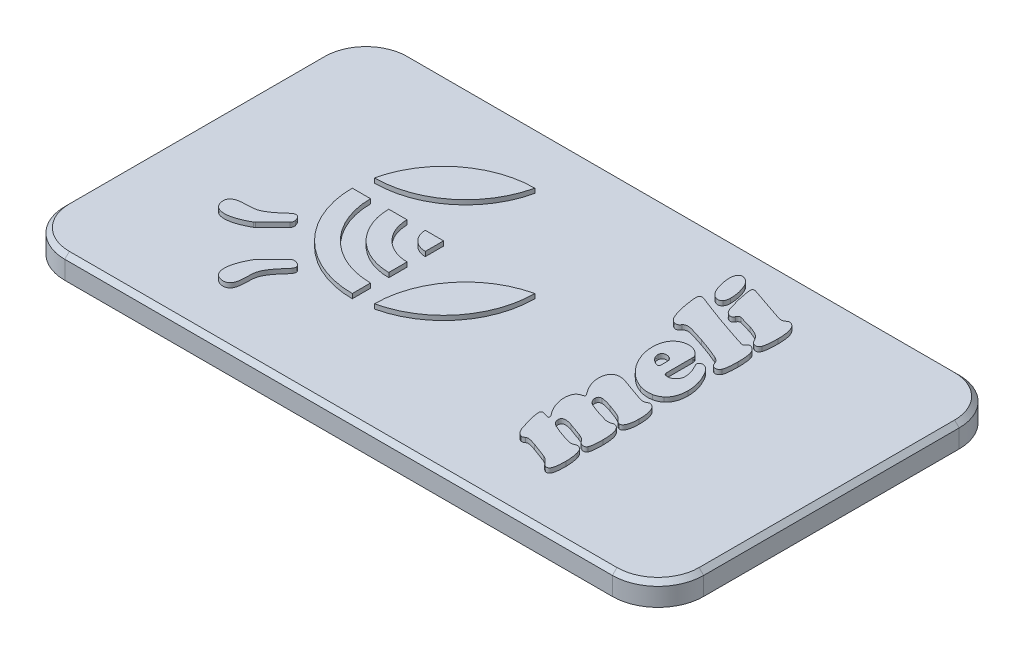
from build123d import *

# Parameters (mm, degrees)
SKETCH1_W           = 140
SKETCH1_H           = 76
BOSS_EXTRUDE1_DEPTH = 5
FILLET1_R           = 10
BOSS_EXTRUDE2_DEPTH = 4
BOSS_EXTRUDE3_DEPTH = 1
BOSS_EXTRUDE4_DEPTH = 1
CHAMFER1_SIZE       = 1
CHAMFER1_SIZE2      = 1.732050808
CHAMFER2_SIZE       = 1


with BuildPart() as part:
    # Sketch1 → Boss-Extrude1 (new body)
    with BuildSketch(Plane(origin=(0, 0, 0), x_dir=(1, 0, 0), z_dir=(0, 1, 0))):
        with Locations((70, 38)):
            Rectangle(SKETCH1_W, SKETCH1_H)
    extrude(amount=BOSS_EXTRUDE1_DEPTH)

    # Fillet1
    fillet1_edges = [part.edges().sort_by_distance(p)[0] for p in [
        (0, 2.5, -76),
        (140, 2.5, -76),
        (140, 2.5, 0),
        (0, 2.5, 0),
    ]]
    fillet(fillet1_edges, radius=FILLET1_R)

    # Sketch3 → Boss-Extrude2 (add)
    with BuildSketch(Plane.XZ):
        with BuildLine():
            Line((5.2, -10), (5.2, -66))
            ThreePointArc((5.2, -66), (6.60588745, -69.39411255), (10, -70.8))
            Line((10, -70.8), (130, -70.8))
            ThreePointArc((130, -70.8), (133.39411255, -69.39411255), (134.8, -66))
            Line((134.8, -66), (134.8, -10))
            ThreePointArc((134.8, -10), (133.39411255, -6.60588745), (130, -5.2))
            Line((130, -5.2), (10, -5.2))
            ThreePointArc((10, -5.2), (6.60588745, -6.60588745), (5.2, -10))
        make_face()
    extrude(amount=BOSS_EXTRUDE2_DEPTH)

    # Sketch4 → Boss-Extrude3 (add)
    with BuildSketch(Plane(origin=(0, 5, 0), x_dir=(1, 0, 0), z_dir=(0, 1, 0))):
        with BuildLine():
            Line((93.75744299, 67.648640731), (100.798454656, 65.255993982))
            add(Edge.make_bspline(
                [(100.798454656, 65.255993982), (100.927750876, 65.212632159), (101.166722633, 65.132488663), (101.501028323, 65.04100066), (101.779213802, 64.985911382), (102.009899704, 64.957677979), (102.211865947, 64.972097631), (102.396898548, 65.024159278), (102.575144929, 65.107802879), (102.679622271, 65.188947152), (102.73347168, 65.230770297)],
                knots=[0, 0, 0, 0, 0.000409091, 0.000756103, 0.001038779, 0.001259646, 0.001451169, 0.00164174, 0.001833533, 0.00203753, 0.00203753, 0.00203753, 0.00203753], degree=3))
            add(Edge.make_bspline(
                [(102.73347168, 65.230770297), (102.81374324, 65.293111417), (102.952677261, 65.401011431), (103.18157613, 65.508967586), (103.424574003, 65.510901816), (103.580209706, 65.462870234), (103.666748047, 65.436163165)],
                knots=[0, 0, 0, 0, 0.000304949, 0.000527806, 0.000744129, 0.001015055, 0.001015055, 0.001015055, 0.001015055], degree=3))
            add(Edge.make_bspline(
                [(103.666748047, 65.436163165), (103.731213011, 65.411534957), (103.859641794, 65.36247), (104.039043833, 65.256108844), (104.201529268, 65.118743483), (104.357172402, 64.961346371), (104.498257245, 64.775766376), (104.623026861, 64.563423892), (104.744137223, 64.329357925), (104.846898934, 64.06561694), (104.936134789, 63.776099336), (105.014853866, 63.462051217), (105.084036038, 63.123248138), (105.1363516, 62.757290393), (105.180521557, 62.365659715), (105.207419542, 61.947180072), (105.226071792, 61.503837726), (105.229074296, 61.199806402), (105.230616554, 61.043638487)],
                knots=[0, 0, 0, 0, 0.000206779, 0.00041195, 0.000621877, 0.000843565, 0.001074913, 0.001319014, 0.00158169, 0.001864733, 0.002166752, 0.002490114, 0.002835682, 0.003203616, 0.003598758, 0.004017743, 0.004461325, 0.004929821, 0.004929821, 0.004929821, 0.004929821], degree=3))
            add(Edge.make_bspline(
                [(105.230616554, 61.043638487), (105.230691629, 60.875455062), (105.230837003, 60.549789434), (105.210169174, 60.076544872), (105.186700222, 59.634279645), (105.151884696, 59.220546753), (105.100584446, 58.838716072), (105.043784482, 58.486231499), (104.976840901, 58.164650202), (104.919439244, 57.962462017), (104.89189849, 57.865454102)],
                knots=[0, 0, 0, 0, 0.000504487, 0.000976874, 0.001420807, 0.00183317, 0.002222018, 0.00257627, 0.002904197, 0.003206646, 0.003206646, 0.003206646, 0.003206646], degree=3))
            add(Edge.make_bspline(
                [(104.89189849, 57.865454102), (104.870039226, 57.806789548), (104.828125162, 57.694303154), (104.732496643, 57.546964913), (104.61366888, 57.42749265), (104.473366542, 57.338093457), (104.315239674, 57.278253495), (104.143908223, 57.257659181), (103.962945634, 57.273219081), (103.844063887, 57.307214745), (103.782056324, 57.324946553)],
                knots=[0, 0, 0, 0, 0.000187376, 0.000359284, 0.000522355, 0.000689281, 0.000854605, 0.001025339, 0.001202492, 0.001395635, 0.001395635, 0.001395635, 0.001395635], degree=3))
            add(Edge.make_bspline(
                [(103.782056324, 57.324946553), (103.683293125, 57.364307529), (103.496152227, 57.438890456), (103.293231234, 57.604597108), (103.153432886, 57.789334291), (103.027796776, 57.992539636), (102.867439184, 58.255099829), (102.757784539, 58.454676612), (102.697437843, 58.564510531)],
                knots=[0, 0, 0, 0, 0.000317609, 0.00060182, 0.000771217, 0.001011106, 0.001318241, 0.001694134, 0.001694134, 0.001694134, 0.001694134], degree=3))
            add(Edge.make_bspline(
                [(102.697437843, 58.564510531), (102.645531185, 58.64652489), (102.539414297, 58.81419333), (102.332620602, 59.04489077), (102.078266793, 59.254368522), (101.778393878, 59.458050237), (101.416896851, 59.652429101), (100.988447696, 59.854436628), (100.480224359, 60.054244627), (100.1142697, 60.182525171), (99.919229043, 60.250894083)],
                knots=[0, 0, 0, 0, 0.000290827, 0.00059456, 0.000924442, 0.001277243, 0.001680435, 0.002154345, 0.00269768, 0.003317713, 0.003317713, 0.003317713, 0.003317713], degree=3))
            add(Edge.make_bspline(
                [(99.919229043, 60.250894083), (99.838861843, 60.277660226), (99.649988701, 60.340564068), (99.319921947, 60.439666541), (98.904441111, 60.567835692), (98.508504977, 60.676420048), (98.178055561, 60.77499692), (97.946819168, 60.838887969), (97.744978499, 60.896380911), (97.57258844, 60.947609837), (97.428510855, 60.987588505), (97.31172202, 61.016596883), (97.223791639, 61.037197602), (97.174641398, 61.049601334), (97.155433779, 61.054448638)],
                knots=[0, 0, 0, 0, 0.000254109, 0.000597188, 0.001033793, 0.001558453, 0.001828707, 0.002068271, 0.002278135, 0.002458304, 0.002607791, 0.002726648, 0.00281929, 0.002878719, 0.002878719, 0.002878719, 0.002878719], degree=3))
            add(Edge.make_bspline(
                [(97.155433779, 61.054448638), (97.076842781, 61.06332278), (96.926387999, 61.080311458), (96.706581601, 60.998062669), (96.523492191, 60.836795764), (96.440027488, 60.690139781), (96.395119827, 60.611232448)],
                knots=[0, 0, 0, 0, 0.000234331, 0.000448603, 0.000681154, 0.000952008, 0.000952008, 0.000952008, 0.000952008], degree=3))
            add(Edge.make_bspline(
                [(96.395119827, 60.611232448), (96.367385127, 60.560169551), (96.314652351, 60.463082207), (96.221733212, 60.33299497), (96.112522381, 60.23507818), (95.993771991, 60.164014329), (95.866293399, 60.119595493), (95.72727033, 60.10546286), (95.579586083, 60.121097711), (95.480699386, 60.149620091), (95.429413007, 60.164412875)],
                knots=[0, 0, 0, 0, 0.000174308, 0.000331418, 0.000476853, 0.000610955, 0.000744281, 0.000878383, 0.001026823, 0.001186758, 0.001186758, 0.001186758, 0.001186758], degree=3))
            add(Edge.make_bspline(
                [(95.429413007, 60.164412875), (95.366206322, 60.189186553), (95.239259886, 60.238942842), (95.060799366, 60.344506752), (94.898441592, 60.480839024), (94.746011035, 60.639392646), (94.609270478, 60.826038791), (94.482434175, 61.036916237), (94.366931935, 61.274199027), (94.30478977, 61.445377364), (94.272726853, 61.533698664)],
                knots=[0, 0, 0, 0, 0.000203456, 0.000408627, 0.000618553, 0.000837738, 0.001066915, 0.001311016, 0.001575319, 0.001857051, 0.001857051, 0.001857051, 0.001857051], degree=3))
            add(Edge.make_bspline(
                [(94.272726853, 61.533698664), (94.104617382, 62.053218735), (93.763733532, 63.106675158), (93.463100671, 64.31559614), (93.290223339, 65.124567129), (93.213171896, 65.502491482), (93.152205349, 65.856003097), (93.103329105, 66.183153248), (93.05707631, 66.483955454), (93.028156583, 66.759314104), (93.014443022, 67.009513362), (93.010027639, 67.166978382), (93.007939189, 67.241458377)],
                knots=[0, 0, 0, 0, 0.00163778, 0.003321008, 0.003733749, 0.004119597, 0.004478003, 0.004809768, 0.005111959, 0.005390913, 0.005639964, 0.00586349, 0.00586349, 0.00586349, 0.00586349], degree=3))
            add(Edge.make_bspline(
                [(93.007939189, 67.241458377), (93.00920326, 67.292209804), (93.011531257, 67.385677046), (93.047949505, 67.51162859), (93.105908048, 67.612363702), (93.194133522, 67.680473539), (93.305448915, 67.715716384), (93.437382981, 67.726209019), (93.591977516, 67.700488543), (93.699026863, 67.666945144), (93.75744299, 67.648640731)],
                knots=[0, 0, 0, 0, 0.000151728, 0.000279432, 0.000389438, 0.000494679, 0.000605216, 0.000735387, 0.000888266, 0.001071897, 0.001071897, 0.001071897, 0.001071897], degree=3))
        make_face()
        with BuildLine():
            add(Edge.make_bspline(
                [(88.395608108, 67.158580553), (88.399719346, 67.324649085), (88.407367351, 67.633581136), (88.480846448, 68.063422373), (88.607987708, 68.421659891), (88.784752301, 68.707918066), (89.008699078, 68.918324305), (89.281013613, 69.030662349), (89.588509978, 69.04799612), (89.789940683, 68.990941763), (89.898219093, 68.960272382)],
                knots=[0, 0, 0, 0, 0.000497906, 0.000926239, 0.001302444, 0.00163132, 0.001927281, 0.002208345, 0.002497178, 0.002832912, 0.002832912, 0.002832912, 0.002832912], degree=3))
            add(Edge.make_bspline(
                [(89.898219093, 68.960272382), (89.977229061, 68.931116964), (90.136043006, 68.872513132), (90.358200684, 68.746352141), (90.572894571, 68.602326797), (90.77616494, 68.432345859), (90.96360548, 68.23305081), (91.134645833, 68.006514228), (91.304723727, 67.762364216), (91.399141673, 67.582529751), (91.447674066, 67.49009185)],
                knots=[0, 0, 0, 0, 0.000252263, 0.00050706, 0.000763914, 0.001027355, 0.001300096, 0.001582634, 0.001878463, 0.002191356, 0.002191356, 0.002191356, 0.002191356], degree=3))
            add(Edge.make_bspline(
                [(91.447674066, 67.49009185), (91.516858042, 67.340766231), (91.655742184, 67.04100086), (91.829271624, 66.576469206), (91.982852338, 66.103562817), (92.105324651, 65.619624851), (92.197940585, 65.124742321), (92.267452995, 64.619819073), (92.306937535, 64.103544029), (92.313020425, 63.755848974), (92.316089527, 63.580420582)],
                knots=[0, 0, 0, 0, 0.000493558, 0.000990799, 0.00148651, 0.001984664, 0.002487139, 0.002996237, 0.003513043, 0.004039335, 0.004039335, 0.004039335, 0.004039335], degree=3))
            add(Edge.make_bspline(
                [(92.316089527, 63.580420582), (92.312666953, 63.44074219), (92.306308451, 63.181245833), (92.242266082, 62.821392601), (92.135816089, 62.518019802), (92.020588371, 62.355704291), (91.966561312, 62.279599082)],
                knots=[0, 0, 0, 0, 0.000418551, 0.00077759, 0.001093478, 0.001372339, 0.001372339, 0.001372339, 0.001372339], degree=3))
            add(Edge.make_bspline(
                [(91.966561312, 62.279599082), (91.928183012, 62.236331323), (91.853418592, 62.152041794), (91.722649762, 62.048854276), (91.579119273, 61.978168336), (91.427608022, 61.922931641), (91.261948879, 61.904615067), (91.086327087, 61.908382317), (90.900885971, 61.937733224), (90.777046193, 61.975350717), (90.7125838, 61.994931773)],
                knots=[0, 0, 0, 0, 0.000173337, 0.000337677, 0.00049561, 0.000651725, 0.000818884, 0.000991884, 0.001177904, 0.001379854, 0.001379854, 0.001379854, 0.001379854], degree=3))
            add(Edge.make_bspline(
                [(90.7125838, 61.994931773), (90.623415958, 62.029136134), (90.443792458, 62.098038856), (90.196160725, 62.260220817), (89.960713493, 62.459174753), (89.74096452, 62.702071065), (89.54021662, 62.987575569), (89.346085816, 63.30921341), (89.176521993, 63.678773021), (89.075188101, 63.941391345), (89.022596864, 64.077687526)],
                knots=[0, 0, 0, 0, 0.000285783, 0.000575693, 0.00088251, 0.001209009, 0.001555009, 0.001928268, 0.002334476, 0.002772758, 0.002772758, 0.002772758, 0.002772758], degree=3))
            add(Edge.make_bspline(
                [(89.022596864, 64.077687526), (88.926708247, 64.3586052), (88.742494735, 64.898281676), (88.550656414, 65.696726213), (88.420572116, 66.443270995), (88.403715373, 66.926277959), (88.395608108, 67.158580553)],
                knots=[0, 0, 0, 0, 0.000889977, 0.001709753, 0.002461514, 0.003158096, 0.003158096, 0.003158096, 0.003158096], degree=3))
        make_face()
        with BuildLine():
            Line((95.35374195, 58.344704128), (99.256206451, 57.018658942))
            add(Edge.make_bspline(
                [(99.256206451, 57.018658942), (99.460216864, 56.948453708), (99.844887306, 56.816078709), (100.391401923, 56.637088868), (100.868862671, 56.477955891), (101.279649157, 56.344605915), (101.621872249, 56.236117999), (101.895616994, 56.152822692), (102.101968078, 56.093823372), (102.283109981, 56.049090702), (102.460043223, 56.031763896), (102.646300506, 56.071559597), (102.806152093, 56.171419791), (102.883908535, 56.268818492), (102.924451014, 56.319602513)],
                knots=[0, 0, 0, 0, 0.000647246, 0.001220411, 0.001725206, 0.002157086, 0.002516071, 0.002802194, 0.003015526, 0.003159751, 0.003362055, 0.003543015, 0.003721009, 0.003914923, 0.003914923, 0.003914923, 0.003914923], degree=3))
            add(Edge.make_bspline(
                [(102.924451014, 56.319602513), (102.954581734, 56.364857555), (103.010663546, 56.44909002), (103.103216774, 56.552996299), (103.192349874, 56.629442333), (103.282279554, 56.680714778), (103.38462602, 56.702884557), (103.499157778, 56.699537703), (103.632018641, 56.682779782), (103.722407864, 56.652864069), (103.771246173, 56.636700274)],
                knots=[0, 0, 0, 0, 0.000162951, 0.000303298, 0.000415871, 0.000514225, 0.000610375, 0.000725683, 0.00085665, 0.001010587, 0.001010587, 0.001010587, 0.001010587], degree=3))
            add(Edge.make_bspline(
                [(103.771246173, 56.636700274), (103.838313447, 56.611201963), (103.974070149, 56.559588614), (104.162805048, 56.44064893), (104.340640914, 56.290209976), (104.507496977, 56.112363271), (104.657081329, 55.910957197), (104.789988314, 55.694753754), (104.889140645, 55.458961911), (104.938943098, 55.295496396), (104.963966163, 55.21336373)],
                knots=[0, 0, 0, 0, 0.000214817, 0.00043483, 0.000665052, 0.000912324, 0.001164561, 0.001416695, 0.001671722, 0.001929257, 0.001929257, 0.001929257, 0.001929257], degree=3))
            add(Edge.make_bspline(
                [(104.963966163, 55.21336373), (104.985327097, 55.129495137), (105.030824366, 54.950861), (105.082662522, 54.66296506), (105.129222941, 54.34206605), (105.169290646, 53.987677504), (105.197662307, 53.599409858), (105.212846467, 53.177509335), (105.230169734, 52.722356128), (105.230463895, 52.407549312), (105.230616554, 52.244175596)],
                knots=[0, 0, 0, 0, 0.000259569, 0.000552863, 0.000876967, 0.001232316, 0.001622548, 0.002044529, 0.002498784, 0.002988857, 0.002988857, 0.002988857, 0.002988857], degree=3))
            add(Edge.make_bspline(
                [(105.230616554, 52.244175596), (105.228617815, 52.061602782), (105.224790684, 51.712017273), (105.212940054, 51.210818596), (105.183572468, 50.756609638), (105.144652833, 50.347924361), (105.095603407, 49.984528675), (105.0347882, 49.66691468), (104.966282151, 49.394460603), (104.902995252, 49.233654383), (104.873881572, 49.159679186)],
                knots=[0, 0, 0, 0, 0.000547762, 0.001048839, 0.00150378, 0.001912887, 0.002280308, 0.002603269, 0.002882967, 0.003121254, 0.003121254, 0.003121254, 0.003121254], degree=3))
            add(Edge.make_bspline(
                [(104.873881572, 49.159679186), (104.845984575, 49.100796311), (104.792001873, 48.986853701), (104.676630234, 48.838589589), (104.537542664, 48.718716155), (104.380281676, 48.625650172), (104.21046272, 48.562794581), (104.032862129, 48.538734052), (103.849552101, 48.542852345), (103.731081488, 48.579014168), (103.670351431, 48.597551336)],
                knots=[0, 0, 0, 0, 0.000195016, 0.00037737, 0.000558724, 0.000742885, 0.000922982, 0.001097774, 0.001278087, 0.001467736, 0.001467736, 0.001467736, 0.001467736], degree=3))
            add(Edge.make_bspline(
                [(103.670351431, 48.597551336), (103.580960445, 48.634376458), (103.4093948, 48.705053897), (103.231223638, 48.869026208), (103.124027754, 49.045318279), (103.03567201, 49.223767259), (102.932963152, 49.446926698), (102.87146171, 49.615560446), (102.837969806, 49.707393502)],
                knots=[0, 0, 0, 0, 0.000288473, 0.000553659, 0.000707595, 0.000905814, 0.00115095, 0.001444067, 0.001444067, 0.001444067, 0.001444067], degree=3))
            add(Edge.make_bspline(
                [(102.837969806, 49.707393502), (102.791965912, 49.800506957), (102.694473139, 49.997835664), (102.439304247, 50.251639478), (102.104243754, 50.489851373), (101.838639934, 50.618355477), (101.695697186, 50.687513857)],
                knots=[0, 0, 0, 0, 0.000309744, 0.000656419, 0.001064414, 0.001539869, 0.001539869, 0.001539869, 0.001539869], degree=3))
            add(Edge.make_bspline(
                [(101.695697186, 50.687513857), (101.55530078, 50.75027832), (101.262137795, 50.881337355), (100.800446513, 51.080234462), (100.29576502, 51.285384981), (99.748005171, 51.496070748), (99.160525485, 51.721188805), (98.529577756, 51.950998171), (97.855796297, 52.189088929), (97.391032483, 52.34678567), (97.151830395, 52.427948163)],
                knots=[0, 0, 0, 0, 0.00046136, 0.000963369, 0.001508053, 0.002095581, 0.002723987, 0.003395426, 0.004109996, 0.004867778, 0.004867778, 0.004867778, 0.004867778], degree=3))
            add(Edge.make_bspline(
                [(97.151830395, 52.427948163), (96.914153938, 52.508857485), (96.461093945, 52.663087219), (95.812635835, 52.87631299), (95.229235388, 53.058652456), (94.714726609, 53.21863292), (94.266858277, 53.349179134), (93.885152245, 53.451707812), (93.568587152, 53.523130515), (93.248733666, 53.587226583), (92.912319668, 53.614748805), (92.556108134, 53.558394094), (92.244992979, 53.421423791), (92.09551724, 53.263698109), (92.020612067, 53.184658731)],
                knots=[0, 0, 0, 0, 0.000753211, 0.001435774, 0.002047766, 0.00258689, 0.003052159, 0.003447219, 0.003772403, 0.004025411, 0.004426181, 0.004776878, 0.005099275, 0.005423119, 0.005423119, 0.005423119, 0.005423119], degree=3))
            add(Edge.make_bspline(
                [(92.020612067, 53.184658731), (91.974036902, 53.12449712), (91.886326215, 53.01120034), (91.741502541, 52.871914633), (91.605448094, 52.762502561), (91.465287499, 52.693117584), (91.319715779, 52.660437771), (91.163242086, 52.657956313), (90.993551933, 52.684893197), (90.877965246, 52.719572451), (90.817081926, 52.737839158)],
                knots=[0, 0, 0, 0, 0.000227926, 0.000429233, 0.000601481, 0.000749746, 0.000893971, 0.001045356, 0.001216583, 0.001407154, 0.001407154, 0.001407154, 0.001407154], degree=3))
            add(Edge.make_bspline(
                [(90.817081926, 52.737839158), (90.724783505, 52.775920188), (90.534570358, 52.854399456), (90.280490841, 53.056581163), (90.041021871, 53.31416254), (89.82436917, 53.643479081), (89.62287808, 54.043526579), (89.43029208, 54.518320325), (89.251335588, 55.074439427), (89.14666691, 55.473437356), (89.091061154, 55.685406989)],
                knots=[0, 0, 0, 0, 0.000298233, 0.000614613, 0.000963919, 0.001350691, 0.001792264, 0.002306172, 0.002886183, 0.003543541, 0.003543541, 0.003543541, 0.003543541], degree=3))
            add(Edge.make_bspline(
                [(89.091061154, 55.685406989), (89.046499557, 55.848428022), (88.95260226, 56.191935337), (88.832281209, 56.740597813), (88.718001371, 57.347761904), (88.610083563, 57.987967167), (88.521465463, 58.60947723), (88.450474903, 59.158054311), (88.407966054, 59.607643049), (88.399361423, 59.874881715), (88.395608108, 59.991450459)],
                knots=[0, 0, 0, 0, 0.000506939, 0.001068188, 0.00168444, 0.002360361, 0.003015701, 0.003567678, 0.004019841, 0.004369667, 0.004369667, 0.004369667, 0.004369667], degree=3))
            add(Edge.make_bspline(
                [(88.395608108, 59.991450459), (88.397766129, 60.064171402), (88.401737666, 60.1980042), (88.46215981, 60.376458937), (88.551630477, 60.522611405), (88.69631535, 60.609611309), (88.870257023, 60.656417757), (89.079683418, 60.661172434), (89.322918031, 60.616421655), (89.49279342, 60.563954817), (89.584724715, 60.535561391)],
                knots=[0, 0, 0, 0, 0.000216952, 0.000399271, 0.000560177, 0.000719094, 0.000891342, 0.001096861, 0.00134152, 0.001630083, 0.001630083, 0.001630083, 0.001630083], degree=3))
            add(Edge.make_bspline(
                [(89.584724715, 60.535561391), (89.621964712, 60.522366959), (89.708630935, 60.491660414), (89.853604881, 60.439757475), (90.028181007, 60.367328101), (90.237391132, 60.292333761), (90.474880961, 60.19053334), (90.746531332, 60.085936633), (91.049541195, 59.965413086), (91.260388682, 59.878768041), (91.372003009, 59.832901578)],
                knots=[0, 0, 0, 0, 0.000118529, 0.000275845, 0.000461864, 0.00068539, 0.000942345, 0.001236766, 0.001558619, 0.001920629, 0.001920629, 0.001920629, 0.001920629], degree=3))
            add(Edge.make_bspline(
                [(91.372003009, 59.832901578), (91.725985408, 59.693858411), (92.418219663, 59.421950984), (93.438238927, 59.038956544), (94.409183962, 58.675483478), (95.044666531, 58.45294075), (95.35374195, 58.344704128)],
                knots=[0, 0, 0, 0, 0.001140913, 0.002231126, 0.003268625, 0.004251035, 0.004251035, 0.004251035, 0.004251035], degree=3))
        make_face()
        with BuildLine():
            Line((99.465202703, 48.139921611), (99.465202703, 42.338473923))
            add(Edge.make_bspline(
                [(99.465202703, 42.338473923), (99.468548063, 42.280030132), (99.474955907, 42.168084436), (99.546636654, 42.016756956), (99.667758842, 41.900412084), (99.770697133, 41.857084487), (99.825541068, 41.834000211)],
                knots=[0, 0, 0, 0, 0.000174308, 0.000333878, 0.000489325, 0.000666588, 0.000666588, 0.000666588, 0.000666588], degree=3))
            add(Edge.make_bspline(
                [(99.825541068, 41.834000211), (99.897070654, 41.811232744), (100.036893031, 41.766728065), (100.252355173, 41.740773678), (100.462806185, 41.73504244), (100.670396686, 41.760825016), (100.874796553, 41.81648614), (101.076566244, 41.898614934), (101.273202132, 42.014077638), (101.465108641, 42.151510421), (101.641860708, 42.312864631), (101.802776103, 42.483611259), (101.932733594, 42.672803689), (102.046705747, 42.868308382), (102.128732257, 43.081864661), (102.190516981, 43.304878525), (102.227405086, 43.540780979), (102.230849519, 43.701625523), (102.232601351, 43.78343077)],
                knots=[0, 0, 0, 0, 0.000224714, 0.000439259, 0.000648286, 0.000855222, 0.001064125, 0.001282271, 0.001506638, 0.001746662, 0.001989055, 0.00222369, 0.002448635, 0.002676134, 0.002900963, 0.003132619, 0.003369594, 0.003614863, 0.003614863, 0.003614863, 0.003614863], degree=3))
            add(Edge.make_bspline(
                [(102.232601351, 43.78343077), (102.229877707, 43.88809708), (102.224186399, 44.106807007), (102.17256012, 44.446041922), (102.097671608, 44.812293126), (101.9886387, 45.194470037), (101.868262657, 45.581252631), (101.723463911, 45.945980723), (101.569564336, 46.285472004), (101.450985079, 46.495159468), (101.393012959, 46.597673406)],
                knots=[0, 0, 0, 0, 0.000313826, 0.000655767, 0.001027493, 0.001434866, 0.001847387, 0.002242184, 0.002611385, 0.002964535, 0.002964535, 0.002964535, 0.002964535], degree=3))
            add(Edge.make_bspline(
                [(101.393012959, 46.597673406), (101.345842594, 46.679825042), (101.259817902, 46.829645151), (101.163012609, 47.044451484), (101.093238045, 47.221629258), (101.083622354, 47.332353084), (101.079518581, 47.379607659)],
                knots=[0, 0, 0, 0, 0.000283845, 0.000517649, 0.000707947, 0.000849629, 0.000849629, 0.000849629, 0.000849629], degree=3))
            add(Edge.make_bspline(
                [(101.079518581, 47.379607659), (101.08263385, 47.432376987), (101.088767013, 47.536266191), (101.171358813, 47.675983401), (101.290170834, 47.798159511), (101.451413115, 47.893934145), (101.634980301, 47.966237997), (101.830080034, 47.998331541), (102.029141909, 47.992271674), (102.156229968, 47.956556567), (102.2217912, 47.938132126)],
                knots=[0, 0, 0, 0, 0.000156447, 0.000308003, 0.000473641, 0.000664621, 0.000865378, 0.001062645, 0.00125376, 0.001457407, 0.001457407, 0.001457407, 0.001457407], degree=3))
            add(Edge.make_bspline(
                [(102.2217912, 47.938132126), (102.292405417, 47.911318827), (102.438652969, 47.855786392), (102.646309331, 47.729607983), (102.85401129, 47.574041584), (103.054820125, 47.379914859), (103.25663212, 47.155667293), (103.459267009, 46.899209672), (103.656607123, 46.606981202), (103.779653101, 46.396618518), (103.843313846, 46.287782411)],
                knots=[0, 0, 0, 0, 0.000226182, 0.000468441, 0.000725724, 0.001003558, 0.001304608, 0.001630451, 0.001983251, 0.002361452, 0.002361452, 0.002361452, 0.002361452], degree=3))
            add(Edge.make_bspline(
                [(103.843313846, 46.287782411), (103.954080612, 46.087350404), (104.173023878, 45.691173466), (104.451772527, 45.07920396), (104.697397179, 44.466603754), (104.889737079, 43.846487981), (105.043526606, 43.22345796), (105.150265857, 42.597205125), (105.218377467, 41.966432535), (105.226527775, 41.544700793), (105.230616554, 41.333129883)],
                knots=[0, 0, 0, 0, 0.000686764, 0.001357468, 0.002015901, 0.002665511, 0.003303503, 0.003939743, 0.004570077, 0.005204641, 0.005204641, 0.005204641, 0.005204641], degree=3))
            add(Edge.make_bspline(
                [(105.230616554, 41.333129883), (105.226962571, 41.126343593), (105.219866649, 40.724770997), (105.151011785, 40.143258071), (105.036204007, 39.604017791), (104.878296243, 39.105477142), (104.672384, 38.647664964), (104.418870063, 38.231979734), (104.122532069, 37.853516659), (103.888516201, 37.639039111), (103.771246173, 37.531560125)],
                knots=[0, 0, 0, 0, 0.000620159, 0.00120433, 0.001753476, 0.002271976, 0.002770299, 0.003255419, 0.003729822, 0.004206355, 0.004206355, 0.004206355, 0.004206355], degree=3))
            add(Edge.make_bspline(
                [(103.771246173, 37.531560125), (103.649044302, 37.434969539), (103.40346398, 37.240858377), (102.981208357, 37.021920108), (102.528447141, 36.839408437), (102.206309168, 36.765691835), (102.041622018, 36.728005569)],
                knots=[0, 0, 0, 0, 0.000466287, 0.000937063, 0.001420857, 0.001926885, 0.001926885, 0.001926885, 0.001926885], degree=3))
            add(Edge.make_bspline(
                [(102.041622018, 36.728005569), (101.813913378, 36.693397101), (101.354148664, 36.623519417), (100.645537176, 36.647122111), (99.919364309, 36.75196426), (99.443242085, 36.897989862), (99.198552312, 36.973035658)],
                knots=[0, 0, 0, 0, 0.000689641, 0.001392449, 0.002117624, 0.002884341, 0.002884341, 0.002884341, 0.002884341], degree=3))
            add(Edge.make_bspline(
                [(99.198552312, 36.973035658), (99.032972638, 37.03297981), (98.700557294, 37.153322817), (98.218448575, 37.380421451), (97.744743608, 37.63453911), (97.287491679, 37.9282587), (96.84179497, 38.253845953), (96.409304918, 38.615693682), (95.987226374, 39.010698639), (95.722006855, 39.296769825), (95.587961888, 39.441353463)],
                knots=[0, 0, 0, 0, 0.000528028, 0.001060061, 0.001596977, 0.002139762, 0.002688956, 0.003251823, 0.003830488, 0.004421817, 0.004421817, 0.004421817, 0.004421817], degree=3))
            add(Edge.make_bspline(
                [(95.587961888, 39.441353463), (95.365913745, 39.699924598), (94.925315508, 40.212993452), (94.371404835, 41.056680839), (93.889521508, 41.933870921), (93.64539289, 42.551755283), (93.523223052, 42.860964553)],
                knots=[0, 0, 0, 0, 0.001021488, 0.002026883, 0.003021639, 0.004018117, 0.004018117, 0.004018117, 0.004018117], degree=3))
            add(Edge.make_bspline(
                [(93.523223052, 42.860964553), (93.442744527, 43.096223204), (93.283343305, 43.562192431), (93.130116541, 44.280504394), (93.026236776, 44.999525614), (93.014032086, 45.481458048), (93.007939189, 45.722051177)],
                knots=[0, 0, 0, 0, 0.000745282, 0.001476156, 0.0021998, 0.002921206, 0.002921206, 0.002921206, 0.002921206], degree=3))
            add(Edge.make_bspline(
                [(93.007939189, 45.722051177), (93.012603391, 45.908342755), (93.021683967, 46.271027431), (93.077143948, 46.798533312), (93.179729731, 47.289823893), (93.313982025, 47.747867988), (93.495095749, 48.168588162), (93.717883024, 48.552067942), (93.971504821, 48.908443631), (94.177114537, 49.111958451), (94.27993362, 49.213729941)],
                knots=[0, 0, 0, 0, 0.000558943, 0.001088186, 0.001588525, 0.00206275, 0.002517919, 0.002958608, 0.003391765, 0.003825041, 0.003825041, 0.003825041, 0.003825041], degree=3))
            add(Edge.make_bspline(
                [(94.27993362, 49.213729941), (94.389409405, 49.307942899), (94.606616716, 49.494867736), (94.972282809, 49.723631031), (95.36725578, 49.903546762), (95.647906857, 49.979099308), (95.789751372, 50.017284496)],
                knots=[0, 0, 0, 0, 0.000432781, 0.000858667, 0.001289298, 0.001729353, 0.001729353, 0.001729353, 0.001729353], degree=3))
            add(Edge.make_bspline(
                [(95.789751372, 50.017284496), (95.952483299, 50.050096765), (96.274528296, 50.115031945), (96.765503914, 50.120994831), (97.251644711, 50.066881451), (97.563657729, 49.974058073), (97.721165013, 49.927199905)],
                knots=[0, 0, 0, 0, 0.000497019, 0.000983596, 0.001466301, 0.001958384, 0.001958384, 0.001958384, 0.001958384], degree=3))
            add(Edge.make_bspline(
                [(97.721165013, 49.927199905), (97.844985335, 49.882171058), (98.086605253, 49.794302878), (98.419209772, 49.614840243), (98.718002433, 49.409527806), (98.975481713, 49.17551637), (99.191568073, 48.930446764), (99.347048648, 48.671929726), (99.4495508, 48.40930645), (99.460058109, 48.228465198), (99.465202703, 48.139921611)],
                knots=[0, 0, 0, 0, 0.000394797, 0.000770397, 0.001130248, 0.001479776, 0.001811992, 0.002106148, 0.002381989, 0.002646611, 0.002646611, 0.002646611, 0.002646611], degree=3))
        make_face()
        with BuildLine():
            Line((97.389653716, 43.444712706), (97.389653716, 44.659052998))
            add(Edge.make_bspline(
                [(97.389653716, 44.659052998), (97.388053777, 44.72052077), (97.38494898, 44.839803362), (97.347541983, 45.009709651), (97.290141237, 45.165167002), (97.205470495, 45.304239051), (97.096644403, 45.427132692), (96.964857448, 45.532639457), (96.810102151, 45.620657037), (96.696105547, 45.66358767), (96.636546532, 45.686017341)],
                knots=[0, 0, 0, 0, 0.00018409, 0.00035724, 0.000519192, 0.000679249, 0.000842638, 0.001009214, 0.001183522, 0.001374229, 0.001374229, 0.001374229, 0.001374229], degree=3))
            add(Edge.make_bspline(
                [(96.636546532, 45.686017341), (96.528156183, 45.720255692), (96.325137721, 45.78438518), (96.023108068, 45.812537958), (95.751061713, 45.793538805), (95.515059668, 45.704775125), (95.32104018, 45.565600482), (95.17764744, 45.374160104), (95.0989235, 45.13190042), (95.088858479, 44.957499444), (95.083488176, 44.864445867)],
                knots=[0, 0, 0, 0, 0.000340057, 0.000636937, 0.000904778, 0.001151077, 0.001383153, 0.001612329, 0.00185619, 0.002135144, 0.002135144, 0.002135144, 0.002135144], degree=3))
            add(Edge.make_bspline(
                [(95.083488176, 44.864445867), (95.09059116, 44.75308704), (95.104805831, 44.530232936), (95.216764304, 44.205032901), (95.39642883, 43.89377285), (95.560307386, 43.709826744), (95.645616026, 43.614071738)],
                knots=[0, 0, 0, 0, 0.000333464, 0.000667336, 0.001020872, 0.00140473, 0.00140473, 0.00140473, 0.00140473], degree=3))
            add(Edge.make_bspline(
                [(95.645616026, 43.614071738), (95.731663578, 43.530504759), (95.897066259, 43.369870297), (96.162160092, 43.168106105), (96.425113584, 43.002551516), (96.611185225, 42.931466173), (96.701407438, 42.89699839)],
                knots=[0, 0, 0, 0, 0.000359491, 0.000691021, 0.000998156, 0.001287259, 0.001287259, 0.001287259, 0.001287259], degree=3))
            add(Edge.make_bspline(
                [(96.701407438, 42.89699839), (96.759752733, 42.877501628), (96.865262045, 42.842244458), (97.015511076, 42.830068861), (97.140850616, 42.832911604), (97.239809168, 42.88537728), (97.314486577, 42.973034886), (97.355309548, 43.099743047), (97.384999322, 43.259504953), (97.387987895, 43.378426301), (97.389653716, 43.444712706)],
                knots=[0, 0, 0, 0, 0.000183631, 0.000332071, 0.000451473, 0.00055301, 0.000657756, 0.000788921, 0.000946525, 0.001145006, 0.001145006, 0.001145006, 0.001145006], degree=3))
        make_face(mode=Mode.SUBTRACT)
        with BuildLine():
            add(Edge.make_bspline(
                [(93.007939189, 20.905547931), (93.010195601, 20.956277625), (93.014329988, 21.049228831), (93.056421073, 21.176508856), (93.138162178, 21.268924727), (93.248092207, 21.327106725), (93.384830203, 21.355909544), (93.550148277, 21.34808854), (93.743401364, 21.310556513), (93.879168992, 21.267416262), (93.952025707, 21.244265995)],
                knots=[0, 0, 0, 0, 0.000152027, 0.000278556, 0.00039347, 0.000512818, 0.000645704, 0.000807896, 0.001005787, 0.001234964, 0.001234964, 0.001234964, 0.001234964], degree=3))
            add(Edge.make_bspline(
                [(93.952025707, 21.244265995), (93.970055075, 21.238296794), (94.036408528, 21.216328353), (94.102256127, 21.192879271), (94.150211808, 21.175801705)],
                knots=[0, 0, 0, 0, 5.6974e-05, 0.000209683, 0.000209683, 0.000209683, 0.000209683], degree=3))
            add(Edge.make_bspline(
                [(94.150211808, 21.175801705), (94.206640627, 21.154117853), (94.307424236, 21.115389824), (94.408439357, 21.077269954), (94.452896036, 21.060493428)],
                knots=[0, 0, 0, 0, 0.000181354, 0.000323905, 0.000323905, 0.000323905, 0.000323905], degree=3))
            add(Edge.make_bspline(
                [(94.452896036, 21.060493428), (94.501913227, 21.045350631), (94.591884924, 21.017555828), (94.719499242, 20.989313617), (94.829323449, 20.98529504), (94.920803633, 20.997578405), (94.994437449, 21.0297301), (95.045945654, 21.085764274), (95.07406914, 21.161451029), (95.077848135, 21.217605436), (95.079884792, 21.247869378)],
                knots=[0, 0, 0, 0, 0.000153937, 0.000282553, 0.000390714, 0.000481945, 0.000557701, 0.000626544, 0.000704163, 0.000794894, 0.000794894, 0.000794894, 0.000794894], degree=3))
            add(Edge.make_bspline(
                [(95.079884792, 21.247869378), (95.071022315, 21.292997245), (95.048836614, 21.405967173), (94.941958838, 21.587854444), (94.787735457, 21.823241504), (94.654071178, 21.990137188), (94.579014464, 22.083854387)],
                knots=[0, 0, 0, 0, 0.000137213, 0.000343489, 0.000624322, 0.000983975, 0.000983975, 0.000983975, 0.000983975], degree=3))
            add(Edge.make_bspline(
                [(94.579014464, 22.083854387), (94.461816144, 22.240319727), (94.226343256, 22.55468725), (93.926664735, 23.068584415), (93.654252193, 23.607425156), (93.427918049, 24.173822188), (93.238070013, 24.746621075), (93.112121879, 25.319462277), (93.021059147, 25.877720848), (93.012259774, 26.247814972), (93.007939189, 26.429535077)],
                knots=[0, 0, 0, 0, 0.000586024, 0.001177429, 0.001781735, 0.002396003, 0.003005657, 0.003589583, 0.004154223, 0.004698918, 0.004698918, 0.004698918, 0.004698918], degree=3))
            add(Edge.make_bspline(
                [(93.007939189, 26.429535077), (93.011024722, 26.595631963), (93.016868322, 26.91019793), (93.088377279, 27.353157495), (93.19064715, 27.745835175), (93.351167176, 28.079928128), (93.551272337, 28.363683272), (93.802242558, 28.586653333), (94.096260512, 28.758179932), (94.315350477, 28.821929494), (94.42767235, 28.854612278)],
                knots=[0, 0, 0, 0, 0.000497737, 0.000942649, 0.001343079, 0.001710553, 0.0020486, 0.002377772, 0.0027103, 0.003060126, 0.003060126, 0.003060126, 0.003060126], degree=3))
            add(Edge.make_bspline(
                [(94.42767235, 28.854612278), (94.505567983, 28.876537802), (94.642699739, 28.9151367), (94.809370532, 28.99101233), (94.928909708, 29.077425099), (94.946163302, 29.155376482), (94.953766364, 29.189726958)],
                knots=[0, 0, 0, 0, 0.000241615, 0.000425352, 0.000555524, 0.000658078, 0.000658078, 0.000658078, 0.000658078], degree=3))
            add(Edge.make_bspline(
                [(94.953766364, 29.189726958), (94.945255117, 29.222587621), (94.921329466, 29.314961016), (94.824477544, 29.474296685), (94.675269451, 29.696838452), (94.55657099, 29.867310054), (94.488929872, 29.964454445)],
                knots=[0, 0, 0, 0, 0.000101472, 0.000285245, 0.000553086, 0.000907923, 0.000907923, 0.000907923, 0.000907923], degree=3))
            add(Edge.make_bspline(
                [(94.488929872, 29.964454445), (94.371877246, 30.133845055), (94.143330297, 30.464582678), (93.837173582, 30.969636669), (93.584957065, 31.477106708), (93.375458227, 31.979931342), (93.210106159, 32.48064214), (93.096847751, 32.979107796), (93.018726186, 33.474091687), (93.011514545, 33.804169258), (93.007939189, 33.967813688)],
                knots=[0, 0, 0, 0, 0.000617641, 0.001205954, 0.001769973, 0.002316025, 0.002839062, 0.003349523, 0.003848419, 0.004338956, 0.004338956, 0.004338956, 0.004338956], degree=3))
            add(Edge.make_bspline(
                [(93.007939189, 33.967813688), (93.010872324, 34.09042792), (93.016553439, 34.327916384), (93.055472937, 34.671919537), (93.123500476, 34.989289734), (93.217463238, 35.28040805), (93.336058658, 35.546478509), (93.484040431, 35.78607998), (93.662124375, 35.99799588), (93.800196067, 36.117172226), (93.869147883, 36.17668787)],
                knots=[0, 0, 0, 0, 0.000367828, 0.000712436, 0.001036841, 0.001339954, 0.00162863, 0.001908606, 0.002182202, 0.002455133, 0.002455133, 0.002455133, 0.002455133], degree=3))
            add(Edge.make_bspline(
                [(93.869147883, 36.17668787), (93.94654607, 36.232754106), (94.10261135, 36.345805759), (94.376267175, 36.458688259), (94.673281255, 36.535533587), (94.998794241, 36.565498077), (95.350324611, 36.556830407), (95.730476014, 36.508595131), (96.138236377, 36.418233353), (96.413846405, 36.328093958), (96.557272091, 36.281185996)],
                knots=[0, 0, 0, 0, 0.000285828, 0.000576342, 0.000881355, 0.001203692, 0.001553295, 0.001934539, 0.002351567, 0.002804061, 0.002804061, 0.002804061, 0.002804061], degree=3))
            add(Edge.make_bspline(
                [(96.557272091, 36.281185996), (96.632861191, 36.254527349), (96.806601341, 36.193252942), (97.103323141, 36.095664507), (97.460957079, 35.958371848), (97.723375365, 35.863860932), (97.865300359, 35.81274612)],
                knots=[0, 0, 0, 0, 0.000240457, 0.000552685, 0.000936898, 0.001389449, 0.001389449, 0.001389449, 0.001389449], degree=3))
            add(Edge.make_bspline(
                [(97.865300359, 35.81274612), (97.898956202, 35.799597286), (97.978317112, 35.768592165), (98.116422414, 35.712505094), (98.295156588, 35.650142083), (98.51372566, 35.573208146), (98.771405739, 35.484933827), (99.067923793, 35.377729329), (99.405663433, 35.265331782), (99.643079434, 35.182472021), (99.76788693, 35.138913376)],
                knots=[0, 0, 0, 0, 0.000108401, 0.000255612, 0.0004471, 0.000676163, 0.000950802, 0.001264213, 0.00162202, 0.002018589, 0.002018589, 0.002018589, 0.002018589], degree=3))
            add(Edge.make_bspline(
                [(99.76788693, 35.138913376), (99.925068934, 35.084377422), (100.213948664, 34.984147554), (100.610998931, 34.853901728), (100.929332067, 34.740003987), (101.116732997, 34.674016843), (101.198430242, 34.645249815)],
                knots=[0, 0, 0, 0, 0.000499117, 0.000917312, 0.00125351, 0.001513353, 0.001513353, 0.001513353, 0.001513353], degree=3))
            add(Edge.make_bspline(
                [(101.198430242, 34.645249815), (101.271684097, 34.617584127), (101.39294085, 34.571789246), (101.514320458, 34.526321087), (101.562371991, 34.508321236)],
                knots=[0, 0, 0, 0, 0.000234912, 0.000388848, 0.000388848, 0.000388848, 0.000388848], degree=3))
            add(Edge.make_bspline(
                [(101.562371991, 34.508321236), (101.686366273, 34.472613811), (101.924001544, 34.404180466), (102.281667354, 34.376628098), (102.619022517, 34.424455167), (102.818005757, 34.516477759), (102.917244246, 34.562371991)],
                knots=[0, 0, 0, 0, 0.000386285, 0.000740317, 0.001068521, 0.00139506, 0.00139506, 0.00139506, 0.00139506], degree=3))
            add(Edge.make_bspline(
                [(102.917244246, 34.562371991), (102.970987621, 34.591794683), (103.068090394, 34.644955187), (103.20174326, 34.708138066), (103.302273445, 34.757193397), (103.403903508, 34.796101721), (103.537689634, 34.799443545), (103.63863289, 34.769974725), (103.695575116, 34.753351325)],
                knots=[0, 0, 0, 0, 0.000183773, 0.000332038, 0.000443277, 0.000519631, 0.000656749, 0.000834195, 0.000834195, 0.000834195, 0.000834195], degree=3))
            add(Edge.make_bspline(
                [(103.695575116, 34.753351325), (103.758679428, 34.728376004), (103.884858354, 34.678437115), (104.06309742, 34.577116444), (104.225409521, 34.448247586), (104.379900777, 34.299218453), (104.51860191, 34.122468607), (104.644685349, 33.922335709), (104.760575355, 33.700738704), (104.865517225, 33.45540111), (104.953914691, 33.183438993), (105.03363426, 32.889067292), (105.097318003, 32.569772101), (105.150969733, 32.227132122), (105.194725932, 31.860639389), (105.221935091, 31.469793164), (105.240489361, 31.055255301), (105.243487401, 30.770433277), (105.245030089, 30.623873654)],
                knots=[0, 0, 0, 0, 0.000203456, 0.000406815, 0.00061224, 0.000823737, 0.001049402, 0.001284314, 0.00153253, 0.001798912, 0.002083785, 0.002389712, 0.002713375, 0.003059937, 0.003430017, 0.003820249, 0.004235029, 0.004674701, 0.004674701, 0.004674701, 0.004674701], degree=3))
            add(Edge.make_bspline(
                [(105.245030089, 30.623873654), (105.243483993, 30.495327259), (105.240476968, 30.245315301), (105.221987578, 29.88241031), (105.195012104, 29.541881478), (105.150479539, 29.224764221), (105.098817319, 28.929359616), (105.029859046, 28.658833958), (104.950339561, 28.412163446), (104.8624273, 28.189331402), (104.761918053, 27.995253222), (104.655923961, 27.830732963), (104.537624025, 27.702287011), (104.416234349, 27.601233914), (104.282129453, 27.538041541), (104.140391875, 27.508427679), (103.990903564, 27.511764783), (103.893345504, 27.539544324), (103.843313846, 27.553790778)],
                knots=[0, 0, 0, 0, 0.000385629, 0.000750017, 0.001089959, 0.001409992, 0.001710372, 0.001989163, 0.002246698, 0.002487586, 0.002706772, 0.002901654, 0.00307254, 0.003228987, 0.003372445, 0.003512375, 0.003660157, 0.00381573, 0.00381573, 0.00381573, 0.00381573], degree=3))
            add(Edge.make_bspline(
                [(103.843313846, 27.553790778), (103.771277726, 27.581163377), (103.639999734, 27.631046962), (103.484873411, 27.730045235), (103.364171914, 27.853108023), (103.222131518, 27.998001769), (103.029247482, 28.202781656), (102.883496545, 28.359648829), (102.801935969, 28.447429925)],
                knots=[0, 0, 0, 0, 0.000230898, 0.000420786, 0.000545663, 0.000746969, 0.001029898, 0.001389389, 0.001389389, 0.001389389, 0.001389389], degree=3))
            add(Edge.make_bspline(
                [(102.801935969, 28.447429925), (102.750390239, 28.497085847), (102.630804844, 28.612286914), (102.392038468, 28.763708852), (102.088191892, 28.933921269), (101.71001824, 29.112387356), (101.259995009, 29.305516158), (100.738562295, 29.513489589), (100.145410933, 29.734404044), (99.723837985, 29.877883449), (99.501236539, 29.953644294)],
                knots=[0, 0, 0, 0, 0.000214273, 0.00049711, 0.000843953, 0.001259765, 0.001750421, 0.002313161, 0.00294367, 0.00364906, 0.00364906, 0.00364906, 0.00364906], degree=3))
            add(Edge.make_bspline(
                [(99.501236539, 29.953644294), (99.370457898, 29.997317042), (99.1204031, 30.080821352), (98.759157817, 30.193894197), (98.427909541, 30.285680052), (98.128976934, 30.36825605), (97.859163884, 30.425674961), (97.620904815, 30.464030589), (97.414456271, 30.494625953), (97.286445002, 30.494301321), (97.227501452, 30.494151842)],
                knots=[0, 0, 0, 0, 0.000413636, 0.000790892, 0.001135387, 0.001444796, 0.001721131, 0.001962235, 0.002169171, 0.002345774, 0.002345774, 0.002345774, 0.002345774], degree=3))
            add(Edge.make_bspline(
                [(97.227501452, 30.494151842), (97.168309625, 30.491584999), (97.055679019, 30.486700793), (96.899270584, 30.444805524), (96.76080889, 30.387324407), (96.654522163, 30.291353676), (96.567648909, 30.176044419), (96.508160466, 30.033808285), (96.471379555, 29.867823267), (96.46864054, 29.749672559), (96.4671875, 29.686993903)],
                knots=[0, 0, 0, 0, 0.000177153, 0.000337088, 0.000483813, 0.00062178, 0.000760873, 0.000914176, 0.001080283, 0.001267971, 0.001267971, 0.001267971, 0.001267971], degree=3))
            add(Edge.make_bspline(
                [(96.4671875, 29.686993903), (96.469695724, 29.619457496), (96.474728827, 29.483936215), (96.524732434, 29.282192778), (96.605750433, 29.083361652), (96.712785229, 28.887140905), (96.843162558, 28.70288256), (96.99411894, 28.539606329), (97.155503513, 28.39176292), (97.277885224, 28.31362143), (97.339206345, 28.27446751)],
                knots=[0, 0, 0, 0, 0.000202304, 0.000405951, 0.000619404, 0.000845155, 0.001075123, 0.001294486, 0.001511438, 0.001729316, 0.001729316, 0.001729316, 0.001729316], degree=3))
            add(Edge.make_bspline(
                [(97.339206345, 28.27446751), (97.382134507, 28.249846973), (97.48148658, 28.1928657), (97.659481475, 28.112078015), (97.882815086, 28.019841282), (98.150489331, 27.911227696), (98.461758749, 27.78829051), (98.82120381, 27.660126262), (99.224556209, 27.515377028), (99.509574433, 27.41546652), (99.65978542, 27.362811444)],
                knots=[0, 0, 0, 0, 0.000148396, 0.000343446, 0.000585705, 0.000873434, 0.001210018, 0.001589607, 0.002018152, 0.002495665, 0.002495665, 0.002495665, 0.002495665], degree=3))
            add(Edge.make_bspline(
                [(99.65978542, 27.362811444), (99.820585531, 27.310683604), (100.124868824, 27.21204169), (100.55796469, 27.079676516), (100.940754306, 26.963107431), (101.273817431, 26.866925901), (101.556964196, 26.786554133), (101.78944464, 26.723802574), (101.973635153, 26.684261507), (102.157921524, 26.651240686), (102.378362603, 26.65097536), (102.661068956, 26.694495235), (102.985581745, 26.778452856), (103.211016985, 26.861010342), (103.331633367, 26.90518172)],
                knots=[0, 0, 0, 0, 0.000507105, 0.000959599, 0.001358583, 0.001707535, 0.001999565, 0.002241663, 0.002429661, 0.002564728, 0.002802579, 0.003086424, 0.003421151, 0.003806325, 0.003806325, 0.003806325, 0.003806325], degree=3))
            add(Edge.make_bspline(
                [(103.331633367, 26.90518172), (103.401501571, 26.920266954), (103.55679893, 26.953797185), (103.709090697, 26.906162112), (103.792866475, 26.879958034)],
                knots=[0, 0, 0, 0, 0.000210975, 0.000468938, 0.000468938, 0.000468938, 0.000468938], degree=3))
            add(Edge.make_bspline(
                [(103.792866475, 26.879958034), (103.851066122, 26.855977101), (103.968516035, 26.807582331), (104.136586135, 26.711128951), (104.286524966, 26.581315555), (104.430893422, 26.433642693), (104.554919752, 26.252998987), (104.673394428, 26.052237041), (104.783912404, 25.826849081), (104.873888118, 25.572742004), (104.962731585, 25.296246861), (105.032044208, 24.99318606), (105.094299086, 24.666387493), (105.143717418, 24.313961843), (105.182781366, 23.935350775), (105.212565736, 23.531641676), (105.224681281, 23.102479835), (105.228601085, 22.808136637), (105.230616554, 22.656792388)],
                knots=[0, 0, 0, 0, 0.000188791, 0.00038099, 0.000577994, 0.000781896, 0.000998878, 0.001233098, 0.001481287, 0.001750361, 0.002040987, 0.002352132, 0.002682172, 0.003038888, 0.003419314, 0.003823921, 0.004252966, 0.00470705, 0.00470705, 0.00470705, 0.00470705], degree=3))
            add(Edge.make_bspline(
                [(105.230616554, 22.656792388), (105.230803665, 22.477792014), (105.231160419, 22.136502551), (105.210070398, 21.650113439), (105.189341329, 21.213390248), (105.146750089, 20.826937347), (105.104487617, 20.486627527), (105.0417477, 20.197507965), (104.978624098, 19.953295541), (104.914149171, 19.815446113), (104.884691723, 19.75246516)],
                knots=[0, 0, 0, 0, 0.000536916, 0.001023707, 0.001460445, 0.001848039, 0.002189981, 0.002488214, 0.002735696, 0.002943883, 0.002943883, 0.002943883, 0.002943883], degree=3))
            add(Edge.make_bspline(
                [(104.884691723, 19.75246516), (104.860868846, 19.710723066), (104.815510862, 19.631247475), (104.727516826, 19.530103548), (104.623853019, 19.457716159), (104.509684073, 19.404569928), (104.380102043, 19.379974676), (104.238965275, 19.382296487), (104.084586739, 19.40347844), (103.981046143, 19.4361012), (103.92619167, 19.453384317)],
                knots=[0, 0, 0, 0, 0.000144, 0.000274172, 0.000398162, 0.00052073, 0.000649346, 0.000789878, 0.000942756, 0.001115004, 0.001115004, 0.001115004, 0.001115004], degree=3))
            add(Edge.make_bspline(
                [(103.92619167, 19.453384317), (103.83881781, 19.485630729), (103.688317216, 19.54117485), (103.511826682, 19.638441714), (103.395907624, 19.755823113), (103.277357089, 19.887899902), (103.114871719, 20.0668313), (102.994989862, 20.20501073), (102.928054397, 20.282162558)],
                knots=[0, 0, 0, 0, 0.000279698, 0.000481777, 0.000596464, 0.00077244, 0.001014833, 0.001321269, 0.001321269, 0.001321269, 0.001321269], degree=3))
            add(Edge.make_bspline(
                [(102.928054397, 20.282162558), (102.848537748, 20.373316257), (102.703949803, 20.539064261), (102.483728213, 20.701593881), (102.291737474, 20.806370783), (102.106224715, 20.890846304), (101.877132457, 20.993193726), (101.705712692, 21.057873532), (101.612819362, 21.092923881)],
                knots=[0, 0, 0, 0, 0.000361956, 0.000658158, 0.000814605, 0.001017709, 0.00126943, 0.001567206, 0.001567206, 0.001567206, 0.001567206], degree=3))
            add(Edge.make_bspline(
                [(101.612819362, 21.092923881), (101.159769915, 21.267361959), (100.253970687, 21.616122734), (99.336456492, 21.932783268), (98.877851167, 22.091061154)],
                knots=[0, 0, 0, 0, 0.001456289, 0.002911614, 0.002911614, 0.002911614, 0.002911614], degree=3))
            add(Edge.make_bspline(
                [(98.877851167, 22.091061154), (98.690175514, 22.151798009), (98.343293482, 22.264058303), (97.851476402, 22.375461983), (97.43414425, 22.424117553), (97.087231929, 22.411244477), (96.809898683, 22.323568931), (96.60333316, 22.162258623), (96.48139799, 21.925031727), (96.472128632, 21.74657608), (96.4671875, 21.651448348)],
                knots=[0, 0, 0, 0, 0.000591581, 0.001093422, 0.001510061, 0.001849469, 0.002127514, 0.002368375, 0.00261659, 0.002899955, 0.002899955, 0.002899955, 0.002899955], degree=3))
            add(Edge.make_bspline(
                [(96.4671875, 21.651448348), (96.46907902, 21.574208175), (96.472787927, 21.422755036), (96.528225087, 21.204014326), (96.604914164, 20.995119673), (96.723692544, 20.80398603), (96.870203997, 20.624756989), (97.048369466, 20.4572279), (97.26283899, 20.3074649), (97.420068861, 20.219526346), (97.50135861, 20.174061048)],
                knots=[0, 0, 0, 0, 0.000231067, 0.000453077, 0.000673238, 0.000896328, 0.001124254, 0.001366432, 0.001627398, 0.001906747, 0.001906747, 0.001906747, 0.001906747], degree=3))
            add(Edge.make_bspline(
                [(97.50135861, 20.174061048), (97.680934959, 20.08985797), (98.070171559, 19.907345517), (98.71455941, 19.641816234), (99.463424909, 19.363437625), (99.999322589, 19.177250108), (100.283170793, 19.078632417)],
                knots=[0, 0, 0, 0, 0.000594951, 0.001289573, 0.002090043, 0.002991502, 0.002991502, 0.002991502, 0.002991502], degree=3))
            add(Edge.make_bspline(
                [(100.283170793, 19.078632417), (100.391204551, 19.042385804), (100.597549688, 18.973154552), (100.892458869, 18.877879566), (101.155671177, 18.786500529), (101.393762712, 18.723261214), (101.59956162, 18.657385983), (101.778459387, 18.613325004), (101.926596709, 18.574861686), (102.086044376, 18.545108141), (102.269809685, 18.533859744), (102.488661099, 18.546471506), (102.709944791, 18.599445807), (102.854152364, 18.654200226), (102.928054397, 18.682260214)],
                knots=[0, 0, 0, 0, 0.000341847, 0.00065293, 0.000929828, 0.00117731, 0.001391643, 0.001577803, 0.001729872, 0.001850733, 0.002063821, 0.002280504, 0.002506025, 0.002743083, 0.002743083, 0.002743083, 0.002743083], degree=3))
            add(Edge.make_bspline(
                [(102.928054397, 18.682260214), (103.011329169, 18.716990162), (103.166484599, 18.781698113), (103.39673731, 18.839089279), (103.605121185, 18.850556766), (103.730709247, 18.821790534), (103.789263091, 18.808378642)],
                knots=[0, 0, 0, 0, 0.00027035, 0.000503709, 0.000709228, 0.000888748, 0.000888748, 0.000888748, 0.000888748], degree=3))
            add(Edge.make_bspline(
                [(103.789263091, 18.808378642), (103.853747814, 18.782545143), (103.983894593, 18.730406487), (104.164501457, 18.619029498), (104.324605617, 18.47285132), (104.475367349, 18.304003281), (104.600926804, 18.098349582), (104.724586076, 17.871713367), (104.817869052, 17.608802174), (104.871290955, 17.423740812), (104.899105258, 17.327387959)],
                knots=[0, 0, 0, 0, 0.000208187, 0.000420175, 0.000632041, 0.000856783, 0.001096672, 0.001352943, 0.001630029, 0.001930993, 0.001930993, 0.001930993, 0.001930993], degree=3))
            add(Edge.make_bspline(
                [(104.899105258, 17.327387959), (104.950011842, 17.105743523), (105.052611835, 16.659028854), (105.154917425, 15.973880264), (105.217670841, 15.272242414), (105.226269679, 14.799147634), (105.230616554, 14.559989311)],
                knots=[0, 0, 0, 0, 0.00068203, 0.001374602, 0.002076337, 0.002793737, 0.002793737, 0.002793737, 0.002793737], degree=3))
            add(Edge.make_bspline(
                [(105.230616554, 14.559989311), (105.230183298, 14.409843264), (105.229351217, 14.121483744), (105.215894507, 13.705607907), (105.187795857, 13.323944469), (105.164018793, 12.974583671), (105.118355436, 12.661349494), (105.070345988, 12.381601926), (105.008105056, 12.136588431), (104.942629211, 11.922982158), (104.862376791, 11.742806909), (104.772259844, 11.593426996), (104.67336665, 11.47123571), (104.557136277, 11.385558925), (104.431682754, 11.329812146), (104.294890559, 11.303882166), (104.146814956, 11.311880505), (104.049444158, 11.341179608), (103.998259343, 11.356581239)],
                knots=[0, 0, 0, 0, 0.000450437, 0.000865077, 0.001247868, 0.001598583, 0.001915045, 0.002197054, 0.002449626, 0.002672977, 0.002866523, 0.00303956, 0.003195508, 0.003334601, 0.003468509, 0.003604199, 0.003748515, 0.00390845, 0.00390845, 0.00390845, 0.00390845], degree=3))
            add(Edge.make_bspline(
                [(103.998259343, 11.356581239), (103.922177694, 11.38711342), (103.774721978, 11.446288589), (103.608672072, 11.567143067), (103.47743223, 11.69369849), (103.362187966, 11.833937672), (103.212141705, 12.004111823), (103.109857039, 12.135468591), (103.054172825, 12.206979783)],
                knots=[0, 0, 0, 0, 0.000245136, 0.000475104, 0.000610171, 0.000791525, 0.001018996, 0.001290806, 0.001290806, 0.001290806, 0.001290806], degree=3))
            add(Edge.make_bspline(
                [(103.054172825, 12.206979783), (102.966849541, 12.307077634), (102.789583718, 12.510275765), (102.464583202, 12.769323295), (102.097558689, 13.001499825), (101.827094317, 13.124213503), (101.688490419, 13.187100137)],
                knots=[0, 0, 0, 0, 0.000397778, 0.000807488, 0.001241393, 0.001697488, 0.001697488, 0.001697488, 0.001697488], degree=3))
            add(Edge.make_bspline(
                [(101.688490419, 13.187100137), (101.18205106, 13.392056395), (100.156787553, 13.806981042), (99.111387665, 14.168201252), (98.582373707, 14.350993058)],
                knots=[0, 0, 0, 0, 0.00163872, 0.003317514, 0.003317514, 0.003317514, 0.003317514], degree=3))
            add(Edge.make_bspline(
                [(98.582373707, 14.350993058), (98.405873259, 14.408743465), (98.082436428, 14.514571006), (97.641560623, 14.657211918), (97.283023741, 14.744473317), (97.002856826, 14.809067199), (96.77365228, 14.822939435), (96.576071411, 14.814454692), (96.400896857, 14.757530397), (96.300455825, 14.697606036), (96.250984481, 14.66809082)],
                knots=[0, 0, 0, 0, 0.000557221, 0.001021107, 0.00138904, 0.001664646, 0.001881329, 0.002076445, 0.00225422, 0.002426769, 0.002426769, 0.002426769, 0.002426769], degree=3))
            add(Edge.make_bspline(
                [(96.250984481, 14.66809082), (96.171003496, 14.615687601), (96.037133119, 14.527976269), (95.836970929, 14.431662481), (95.632574194, 14.439442415), (95.504020222, 14.479238962), (95.429413007, 14.502335172)],
                knots=[0, 0, 0, 0, 0.000288, 0.000482048, 0.000651407, 0.000885627, 0.000885627, 0.000885627, 0.000885627], degree=3))
            add(Edge.make_bspline(
                [(95.429413007, 14.502335172), (95.362293844, 14.529018765), (95.224744864, 14.583702121), (95.034658373, 14.708696551), (94.856406734, 14.866208921), (94.689428281, 15.057105959), (94.530949148, 15.281429099), (94.383980802, 15.541004503), (94.251629363, 15.835448886), (94.173066698, 16.044123192), (94.13219489, 16.152684887)],
                knots=[0, 0, 0, 0, 0.000216233, 0.000443132, 0.000678044, 0.000928213, 0.001202165, 0.001500724, 0.001821608, 0.002169572, 0.002169572, 0.002169572, 0.002169572], degree=3))
            add(Edge.make_bspline(
                [(94.13219489, 16.152684887), (94.04466096, 16.417802902), (93.876360833, 16.927541189), (93.651182163, 17.665668534), (93.451104605, 18.343610319), (93.300331729, 18.967999828), (93.168432912, 19.532123839), (93.0838468, 20.04153025), (93.02501613, 20.492259124), (93.013354818, 20.774481213), (93.007939189, 20.905547931)],
                knots=[0, 0, 0, 0, 0.000837545, 0.001610334, 0.002315162, 0.002957515, 0.003537133, 0.004052518, 0.004506172, 0.004899536, 0.004899536, 0.004899536, 0.004899536], degree=3))
        make_face()
    extrude(amount=BOSS_EXTRUDE3_DEPTH)

    # Sketch5 → Boss-Extrude4 (add)
    with BuildSketch(Plane(origin=(0, 5, 0), x_dir=(1, 0, 0), z_dir=(0, 1, 0))):
        with BuildLine():
            Line((50, 43), (50, 39))
            ThreePointArc((50, 39), (47.171572875, 40.171572875), (46, 43))
            Line((46, 43), (50, 43))
        make_face()
        with BuildLine():
            Line((50, 35), (50, 31))
            ThreePointArc((50, 31), (41.514718626, 34.514718626), (38, 43))
            Line((38, 43), (42, 43))
            ThreePointArc((42, 43), (44.343145751, 37.343145751), (50, 35))
        make_face()
        with BuildLine():
            Line((34, 43), (30, 43))
            ThreePointArc((30, 43), (35.857864376, 28.857864376), (50, 23))
            Line((50, 23), (50, 27))
            ThreePointArc((50, 27), (38.686291501, 31.686291501), (34, 43))
        make_face()
        with BuildLine():
            Line((29.621203274, 29.692271086), (25.847957119, 25.919024931))
            ThreePointArc((25.847957119, 25.919024931), (25.750699278, 25.833614034), (25.643223961, 25.761481064))
            add(Edge.make_bspline(
                [(25.643223961, 25.761481064), (22.647647552, 24.021010991), (18.56447854, 23.196898927), (18.082704215, 27.311416653), (19.22113288, 28.065206072), (21.668908425, 28.351573718), (23.943289196, 28.057050743), (26.6028149, 30.142178131), (28.738643068, 32.170272138), (29.634763671, 31.647856421), (29.884693281, 30.640089051)],
                knots=[0.004098129, 0.004098129, 0.004098129, 0.004098129, 0.326132292, 0.390384464, 0.476515774, 0.501151455, 0.63674127, 0.847835396, 0.912463748, 0.987440191, 0.987440191, 0.987440191, 0.987440191], degree=3))
            ThreePointArc((29.884693281, 30.640089051), (29.877560058, 30.131538439), (29.621203274, 29.692271086))
        make_face()
        with BuildLine():
            Line((36.692271086, 22.621203274), (32.919024931, 18.847957119))
            ThreePointArc((32.919024931, 18.847957119), (32.833614034, 18.750699278), (32.761481064, 18.643223961))
            add(Edge.make_bspline(
                [(32.761481064, 18.643223961), (31.021010991, 15.647647552), (30.196898927, 11.56447854), (34.311416653, 11.082704215), (35.065206072, 12.22113288), (35.351573718, 14.668908425), (35.057050743, 16.943289196), (37.142178131, 19.6028149), (39.170272138, 21.738643068), (38.647856421, 22.634763671), (37.640089051, 22.884693281)],
                knots=[0.004098129, 0.004098129, 0.004098129, 0.004098129, 0.326132292, 0.390384464, 0.476515774, 0.501151455, 0.63674127, 0.847835396, 0.912463748, 0.987440191, 0.987440191, 0.987440191, 0.987440191], degree=3))
            ThreePointArc((37.640089051, 22.884693281), (37.131538439, 22.877560058), (36.692271086, 22.621203274))
        make_face()
        with BuildLine():
            ThreePointArc((50, 63), (37.5, 58.612494996), (30.484381255, 47.375))
            ThreePointArc((30.484381255, 47.375), (42.984381255, 51.762505004), (50, 63))
        make_face()
        with BuildLine():
            ThreePointArc((70, 43), (58.762505004, 35.984381255), (54.375, 23.484381255))
            ThreePointArc((54.375, 23.484381255), (65.612494996, 30.5), (70, 43))
        make_face()
    extrude(amount=BOSS_EXTRUDE4_DEPTH)

    # Chamfer1
    chamfer1_edges = [part.edges().sort_by_distance(p)[0] for p in [
        (6.60588745, -4, -6.60588745),
        (5.2, -4, -38),
        (6.60588745, -4, -69.39411255),
        (70, -4, -70.8),
        (133.39411255, -4, -69.39411255),
        (134.8, -4, -38),
        (133.39411255, -4, -6.60588745),
        (70, -4, -5.2),
    ]]
    chamfer1_side = [part.faces().sort_by_distance(p)[0] for p in [
        (70, -4, -38),
    ]]
    chamfer(chamfer1_edges, length=CHAMFER1_SIZE, length2=CHAMFER1_SIZE2, reference=chamfer1_side[0])

    # Chamfer2
    chamfer2_edges = [part.edges().sort_by_distance(p)[0] for p in [
        (0, 5, -38),
        (70, 5, -76),
        (70, 5, 0),
        (140, 5, -38),
        (2.928932188, 5, -2.928932188),
        (137.071067812, 5, -2.928932188),
        (137.071067812, 5, -73.071067812),
        (2.928932188, 5, -73.071067812),
    ]]
    chamfer(chamfer2_edges, length=CHAMFER2_SIZE)


solid = part.part
